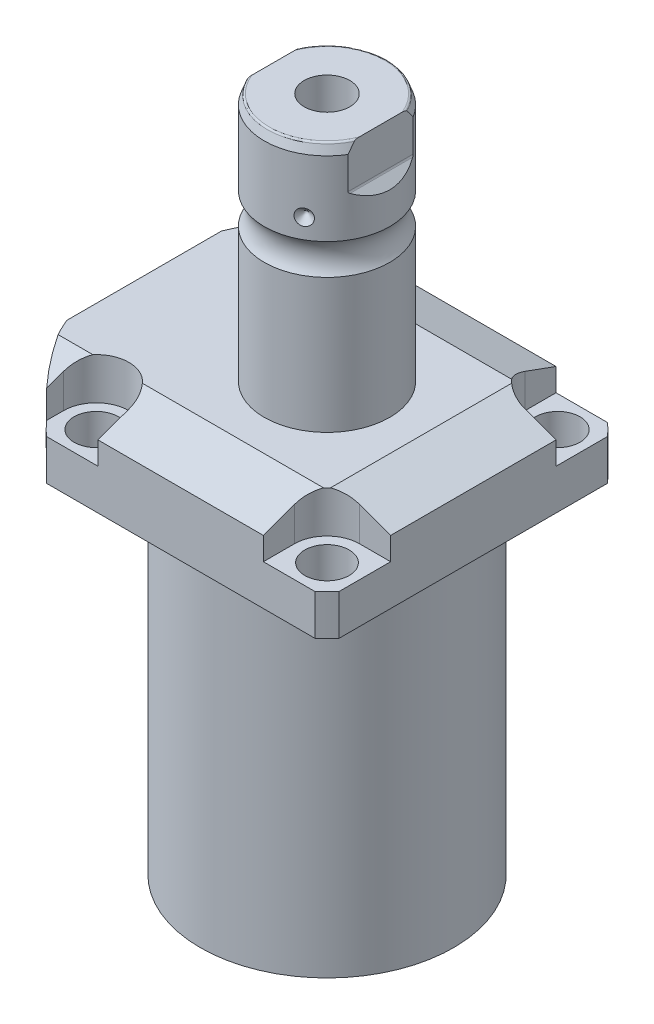
from build123d import *

# Parameters (mm, degrees)
SKETCH1_W               = 88.9
SKETCH1_H               = 99.9998
EXTRUDE1_DEPTH          = 129.794
SKETCH2_OUTSIDE_W       = 139.282
SKETCH2_OUTSIDE_H       = 128.182
SKETCH2_OUTSIDE_R       = 60.325
CUT_EXTRUDE1_DEPTH      = 130.794
SKETCH3_W               = 38.1
SKETCH3_H               = 104.775
FILLET1_R               = 0.381
CUT_EXTRUDE2_DEPTH      = 12.7
CUT_EXTRUDE9_START      = -56.5498
CUT_EXTRUDE9_DEPTH      = 101.9998
CUT_EXTRUDE7_DEPTH      = 45.45
CUT_EXTRUDE7_DEPTH_BACK = 45.45
SKETCH10_R              = 1.1811
SKETCH11_R              = 1.1811
LPATTERN1_COUNT         = 2
LPATTERN1_PITCH         = 25.9588
CUT_EXTRUDE8_DEPTH      = 53.34
SKETCH17_W              = 6.7437
SKETCH17_H              = 12.319
HOLE1_AT_2_COUNT        = 2
HOLE1_AT_2_PITCH        = 70.104
HOLE1_AT_3_COUNT        = 2
HOLE1_AT_3_PITCH        = 99.142027577
HOLE1_AT_4_COUNT        = 2
HOLE1_AT_4_PITCH        = 70.104
CHAMFER1_SIZE           = 0.635
FILLET2_R               = 0.635
CIRPATTERN1_COUNT       = 3


with BuildPart() as part:
    # Sketch1 → Extrude1 (new body)
    with BuildSketch(Plane.ZX):
        with Locations((0, -5.5499)):
            Rectangle(SKETCH1_W, SKETCH1_H)
    extrude(amount=EXTRUDE1_DEPTH)

    # Sketch2 outside → Cut-Extrude1 (cut, through all)
    with BuildSketch(Plane.XZ):
        with Locations((-5.55, 0)):
            Rectangle(SKETCH2_OUTSIDE_W, SKETCH2_OUTSIDE_H)
        Circle(SKETCH2_OUTSIDE_R, mode=Mode.SUBTRACT)
    extrude(amount=-CUT_EXTRUDE1_DEPTH, mode=Mode.SUBTRACT)

    # Sketch3 → Cut-Revolve1 (revolve, cut)
    with BuildSketch(Plane(origin=(0, 0, 0), x_dir=(0, 0, 1), z_dir=(1, 0, 0))):
        with Locations((57.5437, -52.3875)):
            Rectangle(SKETCH3_W, SKETCH3_H)
    revolve(axis=Axis((0, 93.345, 0), (0, -1, 0)), mode=Mode.SUBTRACT)

    # Fillet1
    fillet1_edges = [part.edges().sort_by_distance(p)[0] for p in [
        (0, 104.775, -38.4937),
    ]]
    fillet(fillet1_edges, radius=FILLET1_R)

    # Sketch4 → Cut-Extrude2 (cut)
    with BuildSketch(Plane(origin=(0, 129.794, 0), x_dir=(-1, 0, 0), z_dir=(0, 1, 0))):
        with BuildLine():
            Line((-25.1206, -44.45), (-25.1206, -35.052))
            ThreePointArc((-25.1206, -35.052), (-28.029439713, -28.029439713), (-35.052, -25.1206))
            Line((-35.052, -25.1206), (-44.45, -25.1206))
            Line((-44.45, -25.1206), (-44.45, -44.45))
            Line((-44.45, -44.45), (-25.1206, -44.45))
        make_face()
        with BuildLine():
            Line((44.9834, -44.45), (25.1206, -44.45))
            Line((25.1206, -44.45), (25.1206, -35.052))
            ThreePointArc((25.1206, -35.052), (35.052, -25.1206), (44.9834, -35.052))
            Line((44.9834, -35.052), (44.9834, -44.45))
        make_face()
        with BuildLine():
            Line((25.1206, 44.45), (25.1206, 35.052))
            ThreePointArc((25.1206, 35.052), (35.052, 25.1206), (44.9834, 35.052))
            Line((44.9834, 35.052), (44.9834, 44.45))
            Line((44.9834, 44.45), (25.1206, 44.45))
        make_face()
        with BuildLine():
            Line((-35.052, 25.1206), (-44.45, 25.1206))
            Line((-44.45, 25.1206), (-44.45, 44.45))
            Line((-44.45, 44.45), (-25.1206, 44.45))
            Line((-25.1206, 44.45), (-25.1206, 35.052))
            ThreePointArc((-25.1206, 35.052), (-28.029439713, 28.029439713), (-35.052, 25.1206))
        make_face()
    extrude(amount=-CUT_EXTRUDE2_DEPTH, mode=Mode.SUBTRACT)

    # Sketch5 → Cut-Extrude9 (cut)
    with BuildSketch(Plane(origin=(0, 0, 0), x_dir=(0, 0, -1), z_dir=(1, 0, 0)).offset(CUT_EXTRUDE9_START)):
        Polygon((-28.575, 129.794), (-44.45, 124.015972531), (-44.45, 129.794), align=None)
    cut_extrude9 = extrude(amount=CUT_EXTRUDE9_DEPTH, mode=Mode.SUBTRACT)

    # Mirror1: Cut-Extrude9 across plane
    add(cut_extrude9.mirror(Plane.XY), mode=Mode.SUBTRACT)

    # Sketch9 → Cut-Extrude7 (cut, two sides)
    with BuildSketch(Plane.XY) as cut_extrude7_sk:
        Polygon((28.575, 129.794), (44.45, 124.015972531), (44.45, 129.794), align=None)
    extrude(amount=CUT_EXTRUDE7_DEPTH, mode=Mode.SUBTRACT)
    extrude(cut_extrude7_sk.sketch, amount=-CUT_EXTRUDE7_DEPTH_BACK, mode=Mode.SUBTRACT)

    # Sketch20 → Cut-Revolve4 (revolve, cut)
    with BuildSketch(Plane(origin=(-41.402, 88.9, -18.1102), x_dir=(0, 1, 0), z_dir=(1, 0, 0)), mode=Mode.PRIVATE) as cut_revolve4_sk:
        Polygon((15.875, 41.9227), (17.3228, 41.9227), (17.3228, 39.4716), (18.3388, 39.4716), (18.3388, 37.465), (29.3116, 37.465), (29.3116, 36.2204), (15.875, 36.2204), align=None)
    cut_revolve4 = revolve(cut_revolve4_sk.sketch.rotate(Axis((-41.402, 81.620304954, 18.1102), (0, 1, 0)), 180), axis=Axis((-41.402, 81.620304954, 18.1102), (0, 1, 0)), mode=Mode.SUBTRACT)  # turned: the seam where the file's is

    # Mirror10: Cut-Revolve4 across plane
    add(cut_revolve4.mirror(Plane.XY), mode=Mode.SUBTRACT)

    # S2D0007 → Cut-Revolve2 (revolve, cut)
    with BuildSketch(Plane(origin=(-55.5498, 101.9048, 12.9794), x_dir=(0, 1, 0), z_dir=(0, 0, 1)), mode=Mode.PRIVATE) as cut_revolve2_sk:
        Polygon((15.875, 0), (26.3525, 0), (26.3525, -0.254), (22.0599, -0.254), (21.517306865, -2.8067), (20.8534, -3.470606865), (20.8534, -14.224), (15.875, -14.224), align=None)
    cut_revolve2 = revolve(cut_revolve2_sk.sketch.rotate(Axis((-40.6146, 117.7798, 12.9794), (-1, 0, 0)), 90), axis=Axis((-40.6146, 117.7798, 12.9794), (-1, 0, 0)), mode=Mode.SUBTRACT)  # turned: the seam where the file's is

    # LPattern1: Cut-Revolve2 ×2
    with Locations(*[(0, 0, -i * LPATTERN1_PITCH) for i in range(1, LPATTERN1_COUNT)]):
        add(cut_revolve2, mode=Mode.SUBTRACT)

    # Sketch15 → Revolve3 (revolve)
    with BuildSketch(Plane(origin=(0, 0, 0), x_dir=(0, -1, 0), z_dir=(1, 0, 0)), mode=Mode.PRIVATE) as revolve3_sk:
        with BuildLine():
            Line((-129.794, 0), (-129.794, 19.05))
            Line((-129.794, 19.05), (-170.57830643, 19.05))
            ThreePointArc((-170.57830643, 19.05), (-175.2854, 17.5006), (-179.99249357, 19.05))
            Line((-179.99249357, 19.05), (-202.5396, 19.05))
            Line((-202.5396, 19.05), (-205.4606, 17.986842946))
            Line((-205.4606, 17.986842946), (-205.4606, 0))
            Line((-205.4606, 0), (-129.794, 0))
        make_face()
    revolve(revolve3_sk.sketch.rotate(Axis((0, 197.63613, 0), (0, -1, 0)), 180), axis=Axis((0, 197.63613, 0), (0, -1, 0)))  # turned: the seam where the file's is

    # Sketch16 → Cut-Extrude8 (cut, symmetric)
    with BuildSketch(Plane(origin=(0, 0, 0), x_dir=(0, -1, 0), z_dir=(0, 0, -1))):
        with BuildLine():
            Line((-205.4606, 19.05), (-189.676369265, 19.05))
            Line((-189.676369265, 19.05), (-192.221784633, 16.504584633))
            ThreePointArc((-192.221784633, 16.504584633), (-192.468995225, 16.339403796), (-192.7606, 16.2814))
            Line((-192.7606, 16.2814), (-205.4606, 16.2814))
            Line((-205.4606, 16.2814), (-205.4606, 19.05))
        make_face()
        with BuildLine():
            Line((-205.4606, -19.05), (-205.4606, -16.2814))
            Line((-205.4606, -16.2814), (-192.7606, -16.2814))
            ThreePointArc((-192.7606, -16.2814), (-192.468995225, -16.339403796), (-192.221784633, -16.504584633))
            Line((-192.221784633, -16.504584633), (-189.676369265, -19.05))
            Line((-189.676369265, -19.05), (-205.4606, -19.05))
        make_face()
    extrude(amount=CUT_EXTRUDE8_DEPTH, both=True, mode=Mode.SUBTRACT)

    # Sketch17 → Hole1 (revolve, cut)
    with BuildSketch(Plane(origin=(35.052, 117.094, -35.052), x_dir=(0, 0, 1), z_dir=(1, 0, 0))):
        with Locations((3.37185, 6.1595)):
            Rectangle(SKETCH17_W, SKETCH17_H)
    hole1 = revolve(axis=Axis((35.052, 7.094, -35.052), (0, 1, 0)), mode=Mode.SUBTRACT)

    # Hole1 at 2: Hole1 ×2
    with Locations(*[(0, 0, i * HOLE1_AT_2_PITCH) for i in range(1, HOLE1_AT_2_COUNT)]):
        add(hole1, mode=Mode.SUBTRACT)

    # Hole1 at 3: Hole1 ×2
    with Locations(*[Vector(-0.707106781, 0, 0.707106781) * (i * HOLE1_AT_3_PITCH) for i in range(1, HOLE1_AT_3_COUNT)]):
        add(hole1, mode=Mode.SUBTRACT)

    # Hole1 at 4: Hole1 ×2
    with Locations(*[(-i * HOLE1_AT_4_PITCH, 0, 0) for i in range(1, HOLE1_AT_4_COUNT)]):
        add(hole1, mode=Mode.SUBTRACT)

    # Chamfer1
    chamfer1_edges = [part.edges().sort_by_distance(p)[0] for p in [
        (-41.402, 107.2388, 19.3548),
        (-41.402, 107.2388, -19.3548),
    ]]
    chamfer(chamfer1_edges, length=CHAMFER1_SIZE)

    # Sketch21 → Cut-Revolve5 (revolve, cut)
    with BuildSketch(Plane.XY, mode=Mode.PRIVATE) as cut_revolve5_sk:
        Polygon((0, 180.0606), (6.9342, 184.227087704), (6.9342, 205.4606), (0, 205.4606), align=None)
    revolve(cut_revolve5_sk.sketch.rotate(Axis((0, 0, 0), (0, 1, 0)), 270), axis=Axis((0, 0, 0), (0, 1, 0)), mode=Mode.SUBTRACT)  # turned: the seam where the file's is

    # Fillet2
    fillet2_edges = [part.edges().sort_by_distance(p)[0] for p in [
        (0, 205.4606, 17.986842946),
        (0, 205.4606, -17.986842946),
    ]]
    fillet(fillet2_edges, radius=FILLET2_R)

    # Sketch22 → Cut-Revolve6 (revolve, cut)
    with BuildSketch(Plane.XY, mode=Mode.PRIVATE) as cut_revolve6_sk:
        Polygon((-19.05, 188.3664), (-16.637, 185.9534), (-19.05, 185.9534), align=None)
    cut_revolve6 = revolve(cut_revolve6_sk.sketch.rotate(Axis((-37.997376206, 185.9534, 0), (1, 0, 0)), 90), axis=Axis((-37.997376206, 185.9534, 0), (1, 0, 0)), mode=Mode.SUBTRACT)  # turned: the seam where the file's is

    # CirPattern1: Cut-Revolve6 ×3 about axis
    cirpattern1_axis = Axis((0, 197.63613, 0), (0, 1, 0))
    for i in range(1, CIRPATTERN1_COUNT):
        add(cut_revolve6.rotate(cirpattern1_axis, i * 360 / CIRPATTERN1_COUNT), mode=Mode.SUBTRACT)


with BuildPart() as body_2:
    # Sketch10 → Revolve4 (revolve)
    with BuildSketch(Plane(origin=(-41.402, 88.9, -18.1102), x_dir=(0, 1, 0), z_dir=(1, 0, 0))):
        with Locations((16.1417, 4.5212)):
            Circle(SKETCH10_R)
    revolve(axis=Axis((-41.402, 87.86749, -18.1102), (0, 1, 0)))


with BuildPart() as body_3:
    # Sketch11 → Revolve2 (revolve)
    with BuildSketch(Plane(origin=(-41.402, 88.9, 18.1102), x_dir=(0, 1, 0), z_dir=(1, 0, 0)), mode=Mode.PRIVATE) as revolve2_sk:
        with Locations((16.1417, 4.5212)):
            Circle(SKETCH11_R)
    revolve(revolve2_sk.sketch.rotate(Axis((-41.402, 87.86749, 18.1102), (0, 1, 0)), 180), axis=Axis((-41.402, 87.86749, 18.1102), (0, 1, 0)))  # turned: the seam where the file's is


solid = Compound([part.part, body_2.part, body_3.part])
